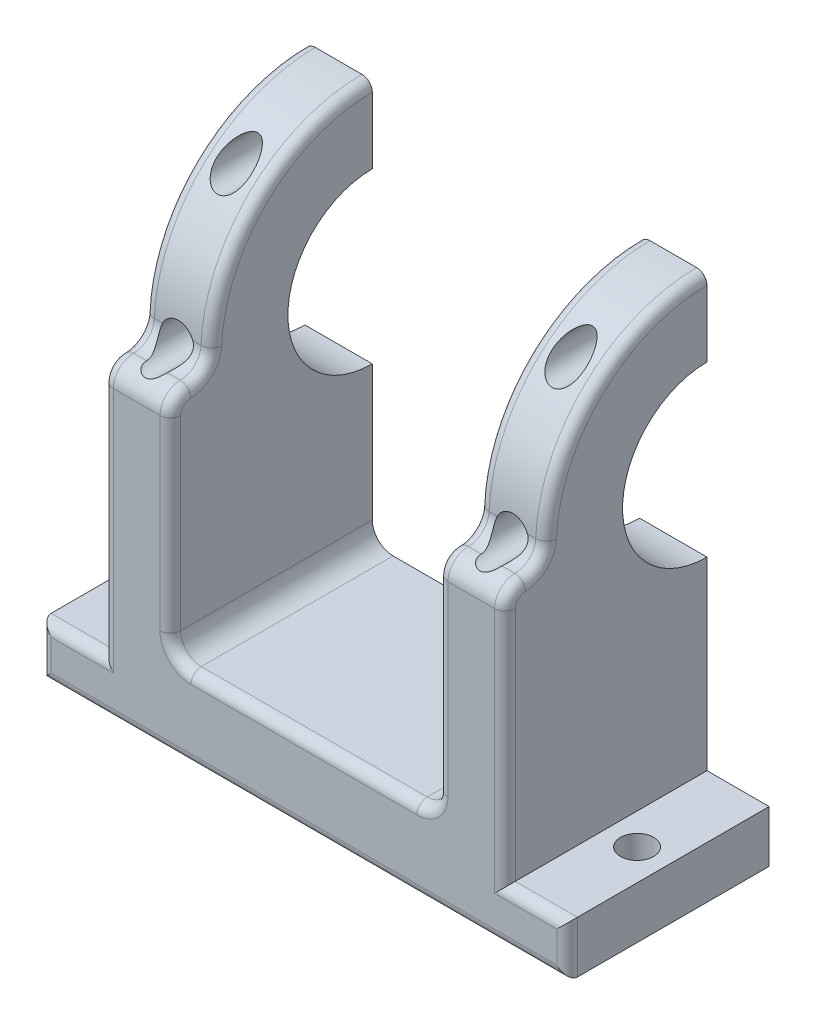
from build123d import *

# Parameters (mm, degrees)
SKETCH3_R               = 15.55
SKETCH3_R_2             = 8.15
BOSS_EXTRUDE4_DEPTH     = 6.5
SKETCH2_R               = 15.55
SKETCH2_R_2             = 8.15
BOSS_EXTRUDE5_DEPTH     = 6.5
CUT_EXTRUDE1_DEPTH      = 38.8
SKETCH5_R               = 1.6
CUT_EXTRUDE2_DEPTH      = 45.598710744
BOSS_EXTRUDE6_DEPTH     = 6.5
SKETCH9_W               = 6.5
SKETCH9_H               = 21.954006421
BOSS_EXTRUDE7_DEPTH     = 4
BOSS_EXTRUDE8_DEPTH     = 6.5
SKETCH12_W              = 6.5
SKETCH12_H              = 21.954006421
BOSS_EXTRUDE9_DEPTH     = 4
FILLET1_R               = 2
FILLET2_R               = 2
CUT_EXTRUDE3_DEPTH      = 50.233423685
SKETCH13_W              = 19.5
SKETCH13_H              = 7.8
BOSS_EXTRUDE10_DEPTH    = 38.8
FILLET3_R               = 2
SKETCH14_W              = 19.5
SKETCH14_H              = 5
BOSS_EXTRUDE11_DEPTH    = 6
SKETCH15_R              = 1.6
CUT_EXTRUDE4_DEPTH      = 65.138073781
SKETCH16_W              = 19.5
SKETCH16_H              = 5
BOSS_EXTRUDE12_DEPTH    = 6
SKETCH17_R              = 1.6
CUT_EXTRUDE5_DEPTH      = 65.138073781
SKETCH19_R              = 2.35
CUT_EXTRUDE7_DEPTH      = 10
FILLET4_R               = 1
SKETCH20_R              = 1.6
CUT_EXTRUDE8_DEPTH      = 57.651532835
CUT_EXTRUDE8_DEPTH_BACK = 57.651532835
FILLET5_R               = 1


with BuildPart() as part:
    # Sketch3 → Boss-Extrude4 (new body)
    with BuildSketch(Plane(origin=(0, 0, 0), x_dir=(0, 0, -1), z_dir=(1, 0, 0))):
        with Locations(Location((0, 0, 0), (0, 0, 180))):
            Circle(SKETCH3_R)
        with Locations(Location((0, 0, 0), (0, 0, 180))):
            Circle(SKETCH3_R_2, mode=Mode.SUBTRACT)
    extrude(amount=BOSS_EXTRUDE4_DEPTH)


with BuildPart() as body_2:
    # Sketch2 → Boss-Extrude5 (new body)
    with BuildSketch(Plane(origin=(32.3, 0, 0), x_dir=(0, 0, -1), z_dir=(1, 0, 0))):
        with Locations(Location((0, 0, 0), (0, 0, 180))):
            Circle(SKETCH2_R)
        with Locations(Location((0, 0, 0), (0, 0, 180))):
            Circle(SKETCH2_R_2, mode=Mode.SUBTRACT)
    extrude(amount=BOSS_EXTRUDE5_DEPTH)


with BuildPart() as cut_extrude1_tool:
    # Sketch4 → Cut-Extrude1 (new body)
    with BuildSketch(Plane(origin=(0, 0, 0), x_dir=(0, 0, -1), z_dir=(1, 0, 0))):
        with BuildLine():
            Line((0, 15.55), (0, -15.55))
            ThreePointArc((0, -15.55), (15.55, 0), (0, 15.55))
        make_face()
    extrude(amount=CUT_EXTRUDE1_DEPTH)


with BuildPart() as part_1:
    add(part.part)

    # Cut-Extrude1: cut by cut_extrude1_tool
    add(cut_extrude1_tool.part, mode=Mode.SUBTRACT)


with BuildPart() as body_2_1:
    add(body_2.part)

    # Cut-Extrude1: cut by cut_extrude1_tool
    add(cut_extrude1_tool.part, mode=Mode.SUBTRACT)


with BuildPart() as cut_extrude2_tool:
    # Sketch5 → Cut-Extrude2 (new, through all)
    with BuildSketch(Plane(origin=(0, 0, 0), x_dir=(-1, 0, 0), z_dir=(0, 0, -1))):
        with Locations((-35.55, 11.85)):
            Circle(SKETCH5_R)
        with Locations((-3.25, 11.85)):
            Circle(SKETCH5_R)
    extrude(amount=-CUT_EXTRUDE2_DEPTH)


with BuildPart() as part_2:
    add(part_1.part)

    # Cut-Extrude2: cut by cut_extrude2_tool
    add(cut_extrude2_tool.part, mode=Mode.SUBTRACT)

    # Sketch11 → Boss-Extrude8 (add)
    with BuildSketch(Plane.ZY):
        with BuildLine():
            ThreePointArc((15.5, -1.245993579), (10.545788255, -11.427547859), (0, -15.55))
            Line((0, -15.55), (0, -23.2))
            Line((0, -23.2), (15.5, -23.2))
            Line((15.5, -23.2), (15.5, -1.245993579))
        make_face()
    extrude(amount=-BOSS_EXTRUDE8_DEPTH)

    # Sketch12 → Boss-Extrude9 (add)
    with BuildSketch(Plane.XY.offset(15.5)):
        with Locations((3.25, -12.22299679)):
            Rectangle(SKETCH12_W, SKETCH12_H)
    extrude(amount=BOSS_EXTRUDE9_DEPTH)

    # Fillet2
    fillet2_edges = [part_2.edges().sort_by_distance(p)[0] for p in [
        (3.25, -1.245993579, 15.5),
    ]]
    fillet(fillet2_edges, radius=FILLET2_R)


with BuildPart() as body_2_2:
    add(body_2_1.part)

    # Cut-Extrude2: cut by cut_extrude2_tool
    add(cut_extrude2_tool.part, mode=Mode.SUBTRACT)

    # Sketch8 → Boss-Extrude6 (add)
    with BuildSketch(Plane(origin=(38.8, 0, 0), x_dir=(0, 0, -1), z_dir=(1, 0, 0))):
        with BuildLine():
            ThreePointArc((0, -19.2), (-8.691551143, -17.120074145), (-15.5, -11.330931118))
            Line((-15.5, -11.330931118), (-15.5, -23.2))
            Line((-15.5, -23.2), (0, -23.2))
            Line((0, -23.2), (0, -19.2))
        make_face()
        with BuildLine():
            ThreePointArc((0, -15.55), (-10.545788255, -11.427547859), (-15.5, -1.245993579))
            Line((-15.5, -1.245993579), (-15.5, -11.330931118))
            ThreePointArc((-15.5, -11.330931118), (-8.691551143, -17.120074145), (0, -19.2))
            Line((0, -19.2), (0, -15.55))
        make_face()
    extrude(amount=-BOSS_EXTRUDE6_DEPTH)

    # Sketch9 → Boss-Extrude7 (add)
    with BuildSketch(Plane.XY.offset(15.5)):
        with Locations((35.55, -12.22299679)):
            Rectangle(SKETCH9_W, SKETCH9_H)
    extrude(amount=BOSS_EXTRUDE7_DEPTH)

    # Fillet1
    fillet1_edges = [body_2_2.edges().sort_by_distance(p)[0] for p in [
        (35.55, -1.245993579, 15.5),
    ]]
    fillet(fillet1_edges, radius=FILLET1_R)


with BuildPart() as cut_extrude3_tool:
    # Sketch10 → Cut-Extrude3 (new, through all)
    with BuildSketch(Plane(origin=(38.8, 0, 0), x_dir=(0, 0, -1), z_dir=(1, 0, 0))):
        with BuildLine():
            Line((-19.5, -3.212198374), (-19.5, -1.245993579))
            Line((-19.5, -1.245993579), (-17.533795206, -1.245993579))
            ThreePointArc((-17.533795206, -1.245993579), (-18.924111949, -1.82188163), (-19.5, -3.212198374))
        make_face()
    extrude(amount=-CUT_EXTRUDE3_DEPTH)


with BuildPart() as part_3:
    add(part_2.part)

    # Cut-Extrude3: cut by cut_extrude3_tool
    add(cut_extrude3_tool.part, mode=Mode.SUBTRACT)



with BuildPart() as body_2_3:
    add(body_2_2.part)

    # Cut-Extrude3: cut by cut_extrude3_tool
    add(cut_extrude3_tool.part, mode=Mode.SUBTRACT)


with BuildPart() as part_4:
    add(part_3.part)

    add(body_2_3.part)  # Boss-Extrude10 merges body 2
    # Sketch13 → Boss-Extrude10 (add)
    with BuildSketch(Plane(origin=(38.8, 0, 0), x_dir=(0, 0, -1), z_dir=(1, 0, 0))):
        with Locations((-9.75, -27.1)):
            Rectangle(SKETCH13_W, SKETCH13_H)
    extrude(amount=-BOSS_EXTRUDE10_DEPTH)

    # Fillet3
    fillet3_edges = [part_4.edges().sort_by_distance(p)[0] for p in [
        (6.5, -23.2, 9.75),
        (32.3, -23.2, 9.75),
    ]]
    fillet(fillet3_edges, radius=FILLET3_R)

    # Sketch14 → Boss-Extrude11 (add)
    with BuildSketch(Plane(origin=(38.8, 0, 0), x_dir=(0, 0, -1), z_dir=(1, 0, 0))):
        with Locations((-9.75, -28.5)):
            Rectangle(SKETCH14_W, SKETCH14_H)
    extrude(amount=BOSS_EXTRUDE11_DEPTH)

    # Sketch15 → Cut-Extrude4 (cut, through all)
    with BuildSketch(Plane(origin=(0, -26, 0), x_dir=(1, 0, 0), z_dir=(0, 1, 0))):
        with Locations(Location((41.8, -9.75, 0), (0, 0, 270))):
            Circle(SKETCH15_R)
    extrude(amount=-CUT_EXTRUDE4_DEPTH, mode=Mode.SUBTRACT)

    # Sketch16 → Boss-Extrude12 (add)
    with BuildSketch(Plane.ZY):
        with Locations((9.75, -28.5)):
            Rectangle(SKETCH16_W, SKETCH16_H)
    extrude(amount=BOSS_EXTRUDE12_DEPTH)

    # Sketch17 → Cut-Extrude5 (cut, through all)
    with BuildSketch(Plane(origin=(0, -26, 0), x_dir=(1, 0, 0), z_dir=(0, 1, 0))):
        with Locations(Location((-3, -9.75, 0), (0, 0, 270))):
            Circle(SKETCH17_R)
    extrude(amount=-CUT_EXTRUDE5_DEPTH, mode=Mode.SUBTRACT)

    # Sketch19 → Cut-Extrude7 (cut)
    with BuildSketch(Plane(origin=(0, 0, 0), x_dir=(-1, 0, 0), z_dir=(0, 0, -1))):
        with Locations((-8.5, -27.1)):
            Circle(SKETCH19_R)
        with Locations((-30.3, -27.1)):
            Circle(SKETCH19_R)
    extrude(amount=-CUT_EXTRUDE7_DEPTH, mode=Mode.SUBTRACT)

    # Fillet4
    fillet4_edges = [part_4.edges().sort_by_distance(p)[0] for p in [
        (6.5, -0.690267327, 16.150294811),
        (6.5, -1.82188163, 18.924111949),
        (6.5, 11.229228387, 10.756715569),
        (0, -0.690267327, 16.150294811),
        (0, 11.229228387, 10.756715569),
        (0, -1.82188163, 18.924111949),
        (19.4, -23.2, 19.5),
        (6.5, -12.206099187, 19.5),
        (31.714213562, -22.614213562, 19.5),
        (7.085786438, -22.614213562, 19.5),
        (38.8, -14.606099187, 19.5),
        (0, -14.606099187, 19.5),
        (32.3, 11.229228387, 10.756715569),
        (38.8, 11.229228387, 10.756715569),
        (38.8, -0.690267327, 16.150294811),
        (32.3, -0.690267327, 16.150294811),
        (32.3, -12.206099187, 19.5),
        (38.8, -1.82188163, 18.924111949),
        (32.3, -1.82188163, 18.924111949),
    ]]
    fillet(fillet4_edges, radius=FILLET4_R)

    # Sketch20 → Cut-Extrude8 (cut, two sides)
    with BuildSketch(Plane.XY.offset(15.535641906)) as cut_extrude8_sk:
        with Locations((3.25, 0)):
            Circle(SKETCH20_R)
        with Locations((35.55, 0)):
            Circle(SKETCH20_R)
    extrude(amount=CUT_EXTRUDE8_DEPTH, mode=Mode.SUBTRACT)
    extrude(cut_extrude8_sk.sketch, amount=-CUT_EXTRUDE8_DEPTH_BACK, mode=Mode.SUBTRACT)

    # Fillet5
    fillet5_edges = [part_4.edges().sort_by_distance(p)[0] for p in [
        (44.8, -28.5, 19.5),
        (41.3, -26, 19.5),
        (19.4, -31, 19.5),
        (-6, -28.5, 19.5),
        (-2.5, -26, 19.5),
    ]]
    fillet(fillet5_edges, radius=FILLET5_R)


solid = part_4.part
